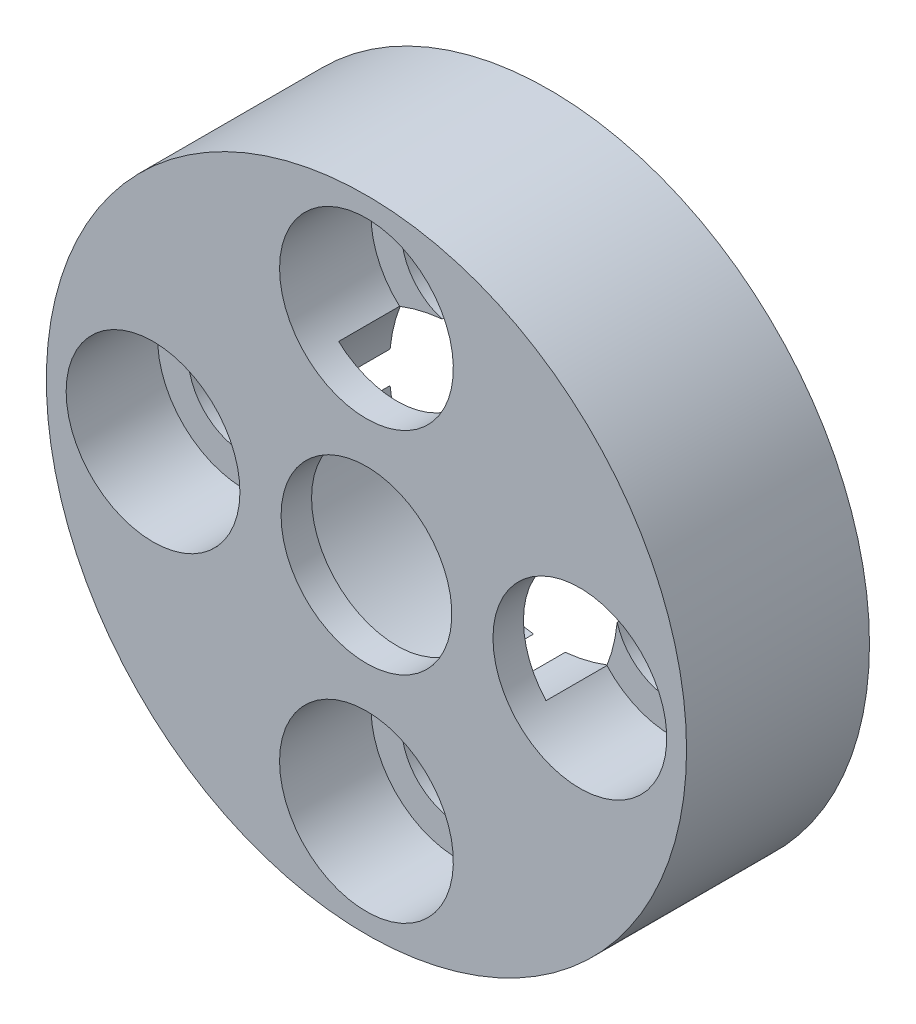
from build123d import *

# Parameters (mm, degrees)
SKETCH1_R           = 10.5
SKETCH1_R_2         = 1.85
BOSS_EXTRUDE1_DEPTH = 6
SKETCH2_R           = 5.25
CUT_EXTRUDE1_DEPTH  = 5
SKETCH3_R           = 2.8
CUT_EXTRUDE2_DEPTH  = 2
SKETCH5_R           = 2.85
SKETCH5_R_2         = 1.85
CUT_EXTRUDE4_DEPTH  = 3


with BuildPart() as part:
    # Sketch1 → Boss-Extrude1 (new body)
    with BuildSketch(Plane.XY):
        Circle(SKETCH1_R)
        with Locations((7, 0)):
            Circle(SKETCH1_R_2, mode=Mode.SUBTRACT)
        with Locations((0, -7)):
            Circle(SKETCH1_R_2, mode=Mode.SUBTRACT)
        with Locations((-7, 0)):
            Circle(SKETCH1_R_2, mode=Mode.SUBTRACT)
        with Locations((0, 7)):
            Circle(SKETCH1_R_2, mode=Mode.SUBTRACT)
    extrude(amount=BOSS_EXTRUDE1_DEPTH)

    # Sketch2 → Cut-Extrude1 (cut)
    with BuildSketch(Plane(origin=(0, 0, 0), x_dir=(-1, 0, 0), z_dir=(0, 0, -1))):
        Circle(SKETCH2_R)
    extrude(amount=-CUT_EXTRUDE1_DEPTH, mode=Mode.SUBTRACT)

    # Sketch3 → Cut-Extrude2 (cut, through all)
    with BuildSketch(Plane(origin=(0, 0, 5), x_dir=(-1, 0, 0), z_dir=(0, 0, -1))):
        Circle(SKETCH3_R)
    extrude(amount=-CUT_EXTRUDE2_DEPTH, mode=Mode.SUBTRACT)

    # Sketch5 → Cut-Extrude4 (cut)
    with BuildSketch(Plane(origin=(0, 0, 6), x_dir=(-1, 0, 0), z_dir=(0, 0, -1))):
        with Locations((0, 7)):
            Circle(SKETCH5_R)
        with Locations((0, 7)):
            Circle(SKETCH5_R_2, mode=Mode.SUBTRACT)
        with Locations((7, 0)):
            Circle(SKETCH5_R)
        with Locations((0, -7)):
            Circle(SKETCH5_R)
        with Locations((-7, 0)):
            Circle(SKETCH5_R)
        with Locations((-7, 0)):
            Circle(SKETCH5_R_2, mode=Mode.SUBTRACT)
    extrude(amount=CUT_EXTRUDE4_DEPTH, mode=Mode.SUBTRACT)


solid = part.part
